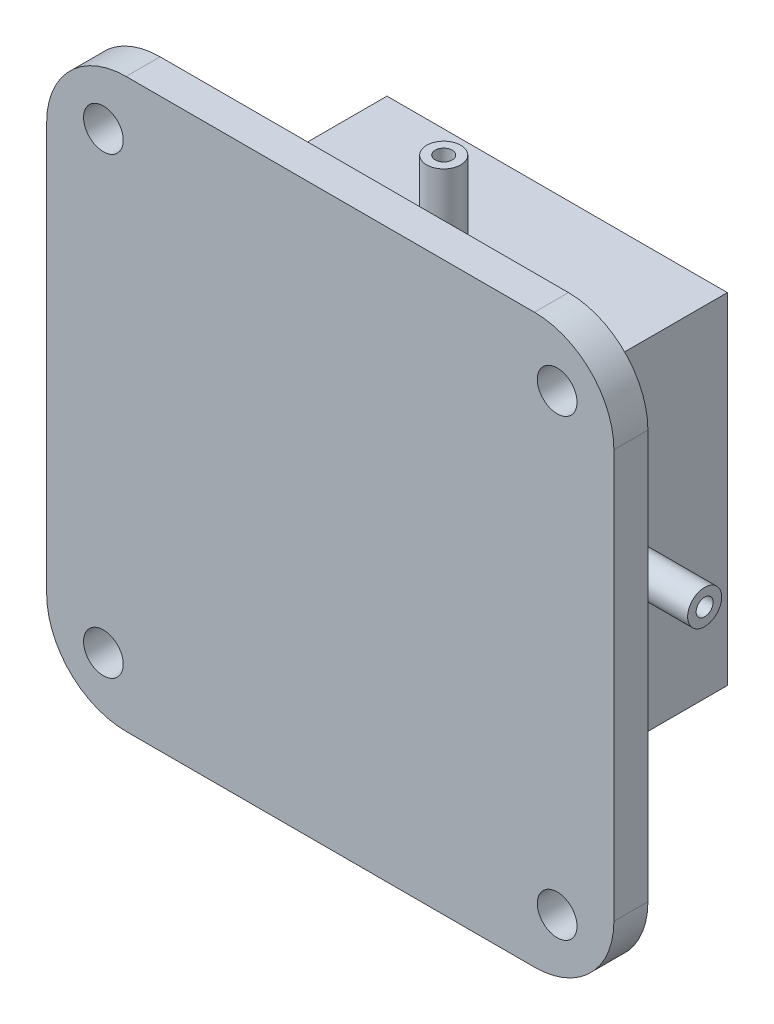
from build123d import *

# Parameters (mm, degrees)
SKETCH_1_R               = 1.75
EXTRUDE_3_DEPTH          = 3
SKETCH_2_W               = 30
SKETCH_2_H               = 30
EXTRUDE_4_DEPTH          = 17
SKETCH_4_R               = 0.75
CUT_EXTRUDE_4_DEPTH      = 9
SKETCH_5_R               = 0.75
CUT_EXTRUDE_5_DEPTH      = 9
SKETCH_17_R              = 0.75
CUT_EXTRUDE_6_DEPTH      = 9
SKETCH_19_R              = 0.75
CUT_EXTRUDE_7_DEPTH      = 9
SKETCH_6_R               = 1.5
SKETCH_6_R_2             = 0.75
EXTRUDE_7_DEPTH          = 8
PATTERN_CIRCULAR_1_COUNT = 4
SKETCH_3_R               = 0.85
CUT_EXTRUDE_8_DEPTH      = 11
SKETCH_21_R              = 1.25
SKETCH_21_R_2            = 0.85
EXTRUDE_8_DEPTH          = 6


with BuildPart() as part:
    # 草图1 → 凸台-拉伸3 (new body)
    with BuildSketch(Plane.XY):
        with BuildLine():
            Line((-18, -25), (18, -25))
            ThreePointArc((18, -25), (22.949747468, -22.949747468), (25, -18))
            Line((25, -18), (25, 18))
            ThreePointArc((25, 18), (22.949747468, 22.949747468), (18, 25))
            Line((18, 25), (-18, 25))
            ThreePointArc((-18, 25), (-22.949747468, 22.949747468), (-25, 18))
            Line((-25, 18), (-25, -18))
            ThreePointArc((-25, -18), (-22.949747468, -22.949747468), (-18, -25))
        make_face()
        with Locations((20, 20)):
            Circle(SKETCH_1_R, mode=Mode.SUBTRACT)
        with Locations((-20, 20)):
            Circle(SKETCH_1_R, mode=Mode.SUBTRACT)
        with Locations((-20, -20)):
            Circle(SKETCH_1_R, mode=Mode.SUBTRACT)
        with Locations((20, -20)):
            Circle(SKETCH_1_R, mode=Mode.SUBTRACT)
    extrude(amount=EXTRUDE_3_DEPTH)

    # 草图2 → 凸台-拉伸4 (add)
    with BuildSketch(Plane.XY):
        Rectangle(SKETCH_2_W, SKETCH_2_H)
    extrude(amount=-EXTRUDE_4_DEPTH)

    # 草图4 → 切除-拉伸4 (cut)
    with BuildSketch(Plane.ZY.offset(15)):
        with Locations((-7, 0)):
            Circle(SKETCH_4_R)
    extrude(amount=-CUT_EXTRUDE_4_DEPTH, mode=Mode.SUBTRACT)

    # 草图5 → 切除-拉伸5 (cut)
    with BuildSketch(Plane(origin=(0, 15, 0), x_dir=(1, 0, 0), z_dir=(0, 1, 0))):
        with Locations((0, 7)):
            Circle(SKETCH_5_R)
    extrude(amount=-CUT_EXTRUDE_5_DEPTH, mode=Mode.SUBTRACT)

    # 草图17 → 切除-拉伸6 (cut)
    with BuildSketch(Plane(origin=(15, 0, 0), x_dir=(0, 0, -1), z_dir=(1, 0, 0))):
        with Locations((7, 0)):
            Circle(SKETCH_17_R)
    extrude(amount=-CUT_EXTRUDE_6_DEPTH, mode=Mode.SUBTRACT)

    # 草图19 → 切除-拉伸7 (cut)
    with BuildSketch(Plane.XZ.offset(15)):
        with Locations((0, -7)):
            Circle(SKETCH_19_R)
    extrude(amount=-CUT_EXTRUDE_7_DEPTH, mode=Mode.SUBTRACT)

    # 草图6 → 凸台-拉伸7 (add)
    with BuildSketch(Plane.ZY.offset(15)):
        with Locations((-7, 0)):
            Circle(SKETCH_6_R)
        with Locations((-7, 0)):
            Circle(SKETCH_6_R_2, mode=Mode.SUBTRACT)
    extrude_7 = extrude(amount=EXTRUDE_7_DEPTH)

    # 阵列(圆周)1: 凸台-拉伸7 ×4 about axis
    pattern_circular_1_axis = Axis((0, 0, 0), (0, 0, 1))
    for i in range(1, PATTERN_CIRCULAR_1_COUNT):
        add(extrude_7.rotate(pattern_circular_1_axis, i * 360 / PATTERN_CIRCULAR_1_COUNT))

    # 草图3 → 切除-拉伸8 (cut)
    with BuildSketch(Plane(origin=(0, 0, -17), x_dir=(-1, 0, 0), z_dir=(0, 0, -1))):
        with Locations((0, -7.5)):
            Circle(SKETCH_3_R)
        with Locations((-7.5, 0)):
            Circle(SKETCH_3_R)
        with Locations((0, 7.5)):
            Circle(SKETCH_3_R)
        with Locations((7.5, 0)):
            Circle(SKETCH_3_R)
    extrude(amount=-CUT_EXTRUDE_8_DEPTH, mode=Mode.SUBTRACT)

    # 草图21 → 凸台-拉伸8 (add)
    with BuildSketch(Plane(origin=(0, 0, -17), x_dir=(-1, 0, 0), z_dir=(0, 0, -1))):
        with Locations((-7.5, 0)):
            Circle(SKETCH_21_R)
        with Locations((-7.5, 0)):
            Circle(SKETCH_21_R_2, mode=Mode.SUBTRACT)
        with Locations((0, -7.5)):
            Circle(SKETCH_21_R)
        with Locations((0, -7.5)):
            Circle(SKETCH_21_R_2, mode=Mode.SUBTRACT)
        with Locations((7.5, 0)):
            Circle(SKETCH_21_R)
        with Locations((7.5, 0)):
            Circle(SKETCH_21_R_2, mode=Mode.SUBTRACT)
        with Locations((0, 7.5)):
            Circle(SKETCH_21_R)
        with Locations((0, 7.5)):
            Circle(SKETCH_21_R_2, mode=Mode.SUBTRACT)
    extrude(amount=EXTRUDE_8_DEPTH)


solid = part.part
